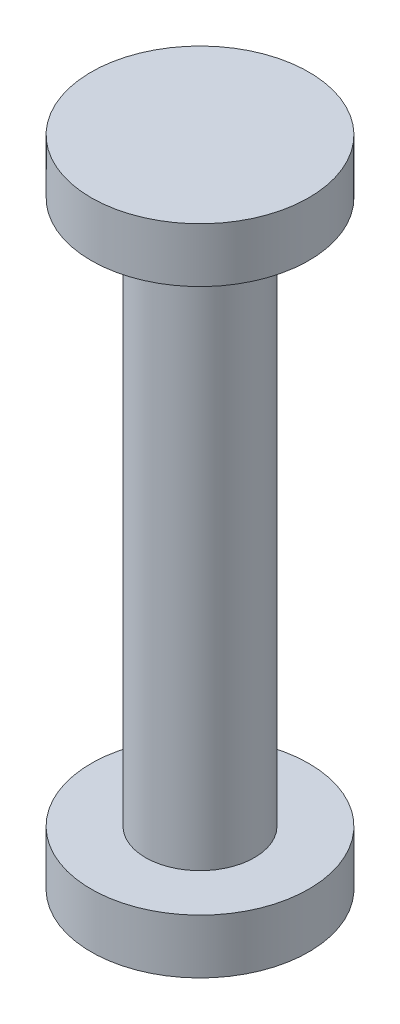
from build123d import *

# Parameters (mm, degrees)
SKETCH1_R           = 5
BOSS_EXTRUDE2_DEPTH = 50
SKETCH2_R           = 10
BOSS_EXTRUDE3_DEPTH = 5
SKETCH3_R           = 10
BOSS_EXTRUDE4_DEPTH = 5


with BuildPart() as part:
    # Sketch1 → Boss-Extrude2 (new body)
    with BuildSketch(Plane(origin=(0, 0, 0), x_dir=(1, 0, 0), z_dir=(0, 1, 0))):
        Circle(SKETCH1_R)
    extrude(amount=BOSS_EXTRUDE2_DEPTH)

    # Sketch2 → Boss-Extrude3 (add)
    with BuildSketch(Plane(origin=(0, 50, 0), x_dir=(1, 0, 0), z_dir=(0, 1, 0))):
        Circle(SKETCH2_R)
    extrude(amount=BOSS_EXTRUDE3_DEPTH)

    # Sketch3 → Boss-Extrude4 (add)
    with BuildSketch(Plane(origin=(0, 0, 0), x_dir=(-1, 0, 0), z_dir=(0, -1, 0))):
        Circle(SKETCH3_R)
    extrude(amount=BOSS_EXTRUDE4_DEPTH)


solid = part.part
